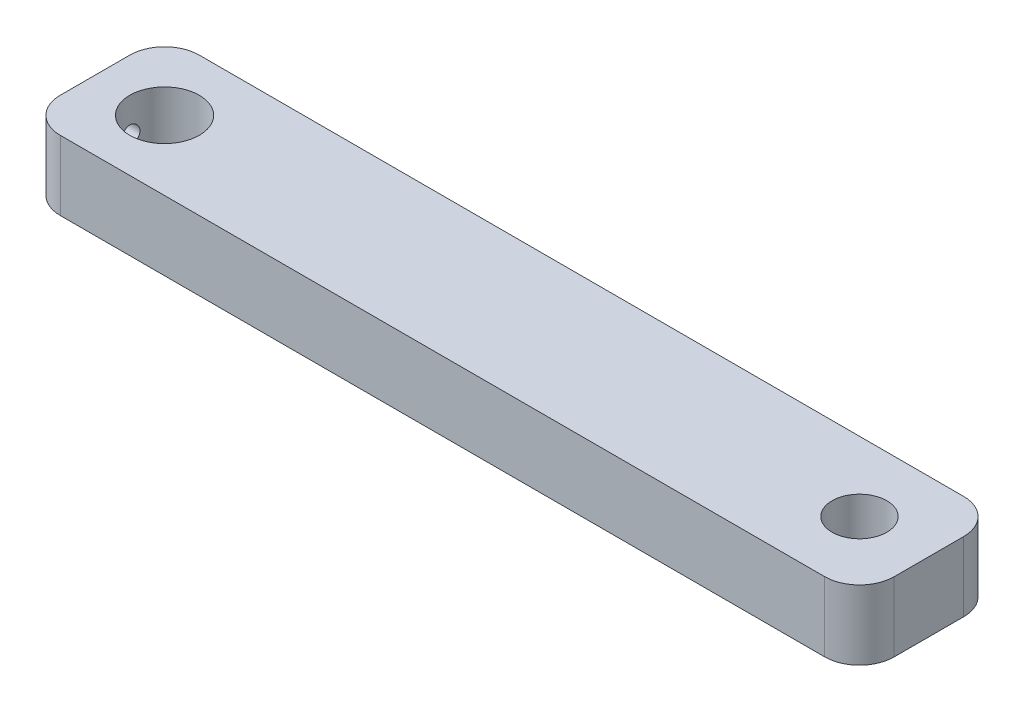
from build123d import *

# Parameters (mm, degrees)
SKETCH1_W                        = 152.4
SKETCH1_H                        = 25.4
SKETCH1_R                        = 6.35
SKETCH1_R_2                      = 5
BOSS_EXTRUDE1_DEPTH              = 12.7
FILLET1_R                        = 6.35
TAP_DRILL_FOR_M4X0_7_TAP1_REACH  = 155.455
TAP_DRILL_FOR_M4X0_7_TAP1_BORE_R = 1.65


with BuildPart() as part:
    # Sketch1 → Boss-Extrude1 (new body)
    with BuildSketch(Plane(origin=(0, 0, 0), x_dir=(1, 0, 0), z_dir=(0, 1, 0))):
        with Locations((63.5, 0)):
            Rectangle(SKETCH1_W, SKETCH1_H)
        with Locations(Location((0, 0, 0), (0, 0, 270))):
            Circle(SKETCH1_R, mode=Mode.SUBTRACT)
        with Locations(Location((127, 0, 0), (0, 0, 270))):
            Circle(SKETCH1_R_2, mode=Mode.SUBTRACT)
    extrude(amount=BOSS_EXTRUDE1_DEPTH)

    # Fillet1
    fillet1_edges = [part.edges().sort_by_distance(p)[0] for p in [
        (-12.7, 6.35, -12.7),
        (139.7, 6.35, -12.7),
        (139.7, 6.35, 12.7),
        (-12.7, 6.35, 12.7),
    ]]
    fillet(fillet1_edges, radius=FILLET1_R)

    # Tap Drill for M4x0.7 Tap1 bore → Tap Drill for M4x0.7 Tap1 (cut, up to next)
    with BuildSketch(Plane.ZY.offset(12.7), mode=Mode.PRIVATE) as tap_drill_for_m4x0_7_tap1_sk1:
        with Locations((0, 6.35)):
            Circle(TAP_DRILL_FOR_M4X0_7_TAP1_BORE_R)
    tap_drill_for_m4x0_7_tap1_tool1 = extrude(tap_drill_for_m4x0_7_tap1_sk1.sketch, amount=-TAP_DRILL_FOR_M4X0_7_TAP1_REACH, mode=Mode.PRIVATE) & part.part
    add(tap_drill_for_m4x0_7_tap1_tool1.solids().sort_by_distance((-12.7, 6.35, 0))[0], mode=Mode.SUBTRACT)


solid = part.part
